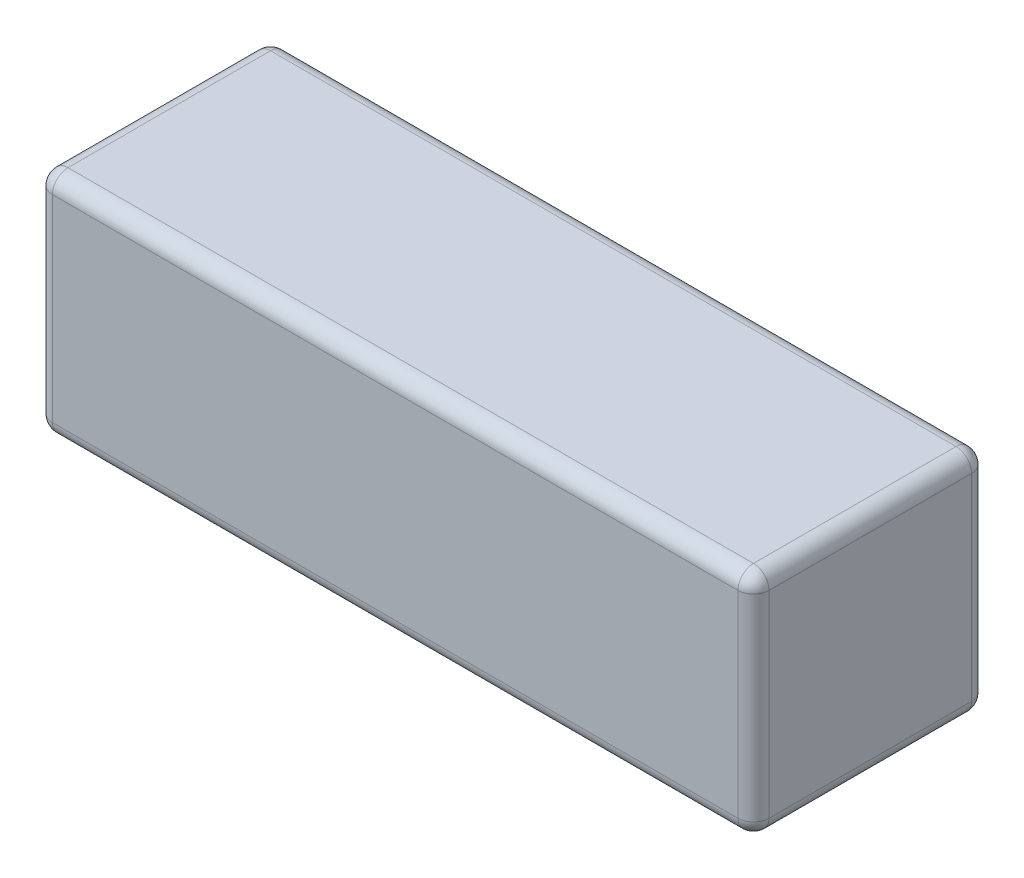
from build123d import *

# Parameters (mm, degrees)
SKETCH_1_W      = 138
SKETCH_1_H      = 44
EXTRUDE_1_DEPTH = 45
FILLET_1_R      = 3


with BuildPart() as part:
    # 草图1 → 凸台-拉伸1 (new body)
    with BuildSketch(Plane.XY):
        Rectangle(SKETCH_1_W, SKETCH_1_H)
    extrude(amount=EXTRUDE_1_DEPTH)

    # 圆角1
    fillet_1_edges = [part.edges().sort_by_distance(p)[0] for p in [
        (69, 0, 45),
        (0, 22, 45),
        (-69, 0, 45),
        (0, 22, 0),
        (69, 0, 0),
        (0, -22, 0),
        (-69, 0, 0),
        (-69, 22, 22.5),
        (69, 22, 22.5),
        (69, -22, 22.5),
        (-69, -22, 22.5),
        (0, -22, 45),
    ]]
    fillet(fillet_1_edges, radius=FILLET_1_R)


solid = part.part
